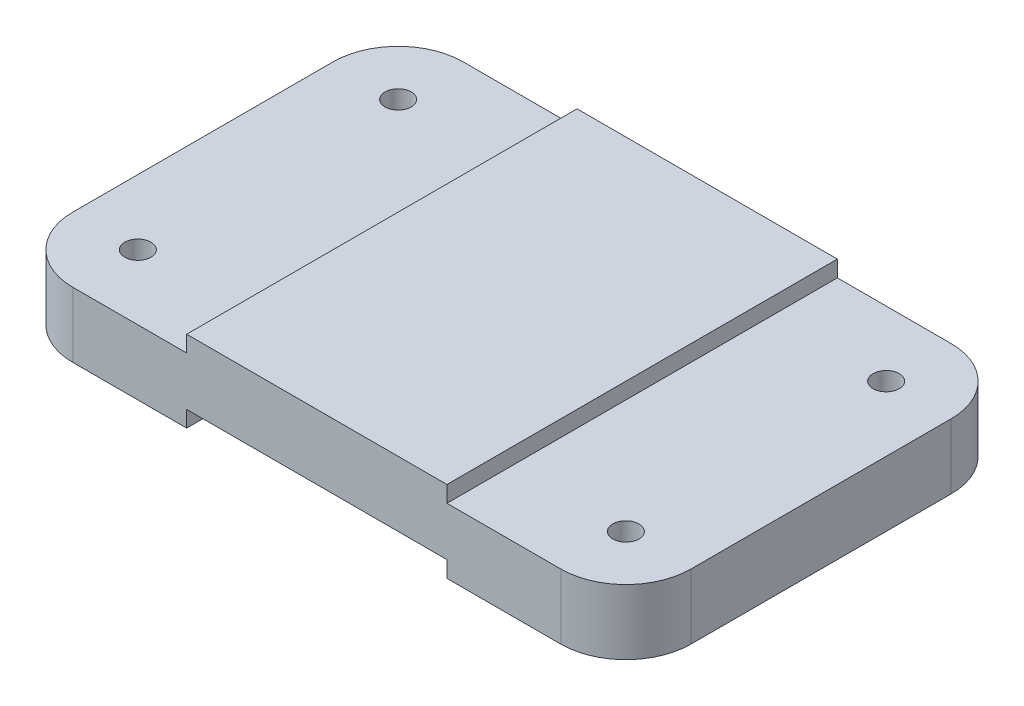
from build123d import *

# Parameters (mm, degrees)
BOSS_EXTRUDE1_DEPTH         = 76.2
FILLET1_R                   = 12.7
F_1_4_20_TAPPED_HOLE3_D     = 5.1054
F_1_4_20_TAPPED_HOLE3_DEPTH = 16.51
F_1_4_20_TAPPED_HOLE3_TIP   = 1.533816902


with BuildPart() as part:
    # Sketch1 → Boss-Extrude1 (new body)
    with BuildSketch(Plane.XY):
        Polygon((-3.386666667, 0), (31.538333333, 0), (31.538333333, 3.175), (82.338333333, 3.175), (82.338333333, 0), (117.263333333, 0), (117.263333333, 12.7), (82.338333333, 12.7), (82.338333333, 15.875), (31.538333333, 15.875), (31.538333333, 12.7), (-3.386666667, 12.7), align=None)
    extrude(amount=-BOSS_EXTRUDE1_DEPTH)

    # Fillet1
    fillet1_edges = [part.edges().sort_by_distance(p)[0] for p in [
        (117.263333333, 6.35, 0),
        (-3.386666667, 6.35, 0),
        (117.263333333, 6.35, -76.2),
        (-3.386666667, 6.35, -76.2),
    ]]
    fillet(fillet1_edges, radius=FILLET1_R)

    # 1/4-20 Tapped Hole3
    with Locations(Plane(origin=(0, 12.7, 0), x_dir=(1, 0, 0), z_dir=(0, 1, 0))):
        with Locations((104.563333333, 63.5), (104.563333333, 12.7), (9.313333333, 12.7), (9.313333333, 63.5)):
            Hole(F_1_4_20_TAPPED_HOLE3_D / 2, depth=F_1_4_20_TAPPED_HOLE3_DEPTH)
            with Locations((0, 0, -(F_1_4_20_TAPPED_HOLE3_DEPTH + F_1_4_20_TAPPED_HOLE3_TIP / 2))):  # 118° drill point
                Cone(0, F_1_4_20_TAPPED_HOLE3_D / 2, F_1_4_20_TAPPED_HOLE3_TIP, mode=Mode.SUBTRACT)


solid = part.part
